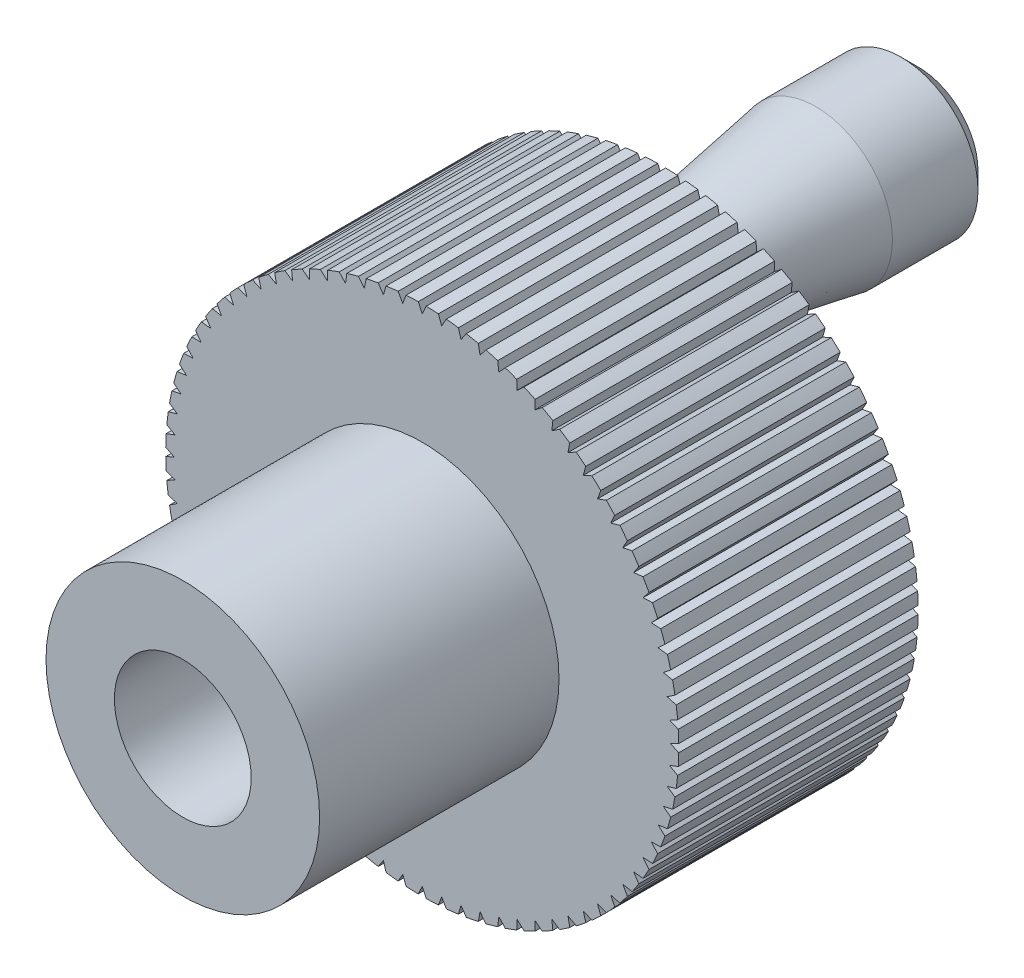
from build123d import *

# Parameters (mm, degrees)
SKETCH_1_R               = 8
SKETCH_1_R_2             = 4
EXTRUDE_1_DEPTH          = 14
SKETCH_2_R               = 15
EXTRUDE_2_DEPTH          = 14
CHAMFER_1_SIZE           = 1
CUT_EXTRUDE_1_DEPTH      = 29
PATTERN_CIRCULAR_1_COUNT = 80


with BuildPart() as part:
    # 草图1 → 凸台-拉伸1 (new body)
    with BuildSketch(Plane.XY):
        Circle(SKETCH_1_R)
        Circle(SKETCH_1_R_2, mode=Mode.SUBTRACT)
    extrude(amount=EXTRUDE_1_DEPTH)

    # 草图2 → 凸台-拉伸2 (add)
    with BuildSketch(Plane(origin=(0, 0, 0), x_dir=(-1, 0, 0), z_dir=(0, 0, -1))):
        Circle(SKETCH_2_R)
    extrude(amount=EXTRUDE_2_DEPTH)

    # 草图4 → 旋转1 (revolve)
    with BuildSketch(Plane(origin=(0, 0, 0), x_dir=(0, 0, -1), z_dir=(1, 0, 0))):
        Polygon((14, 9), (29, 9), (29, 13.5), (23, 13.5), (14, 12), align=None)
    revolve(axis=Axis((0, 9, -14), (0, 0, -1)))

    # 倒角1
    chamfer_1_edges = [part.edges().sort_by_distance(p)[0] for p in [
        (0, 4.5, -29),
    ]]
    chamfer(chamfer_1_edges, length=CHAMFER_1_SIZE)

    # 草图5 → 切除-拉伸1 (cut, through all)
    with BuildSketch(Plane(origin=(0, 0, -14), x_dir=(-1, 0, 0), z_dir=(0, 0, -1))):
        with BuildLine():
            Line((-14.5, 0), (-14.998200885, 0.232314888))
            ThreePointArc((-14.998200885, 0.232314888), (-15, 0), (-14.998200885, -0.232314888))
            Line((-14.998200885, -0.232314888), (-14.5, 0))
        make_face()
    cut_extrude_1 = extrude(amount=-CUT_EXTRUDE_1_DEPTH, mode=Mode.SUBTRACT)

    # 阵列(圆周)1: 切除-拉伸1 ×80 about axis
    pattern_circular_1_axis = Axis((0, 0, 0), (0, 0, 1))
    for i in range(1, PATTERN_CIRCULAR_1_COUNT):
        add(cut_extrude_1.rotate(pattern_circular_1_axis, i * 360 / PATTERN_CIRCULAR_1_COUNT), mode=Mode.SUBTRACT)


solid = part.part
